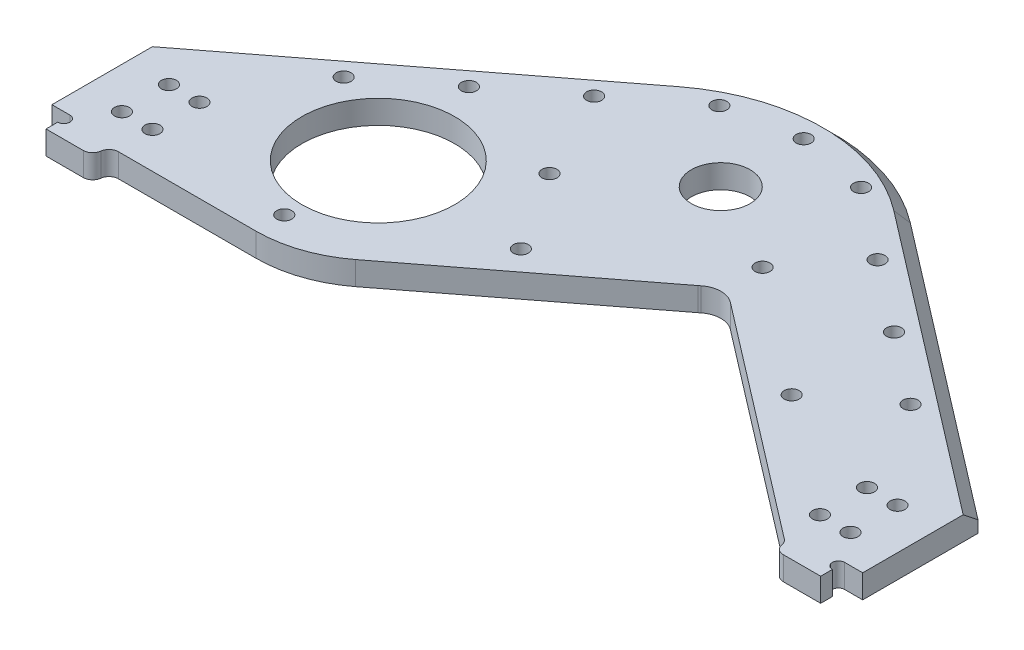
from build123d import *

# Parameters (mm, degrees)
SKETCH3_R                          = 17.8
SKETCH3_R_2                        = 7.9375
BOSS_EXTRUDE1_DEPTH                = 6.35
SKETCH7_R                          = 20.6375
CUT_EXTRUDE1_DEPTH                 = 7.35
SKETCH8_W                          = 4.7498
SKETCH8_H                          = 41.275
BOSS_EXTRUDE4_DEPTH                = 6.35
SKETCH10_R                         = 2.0193
SPACER_HOLES_DEPTH                 = 7.35
SPACER_HOLE_PATTERN_COUNT          = 5
SPACER_HOLE_PATTERN_PITCH          = 24.13
SPACER_HOLE_MIRROR_COPY_1_SKETCH_R = 2.0193
SPACER_HOLE_MIRROR_COPY_1_DEPTH    = 7.35
SPACER_HOLE_MIRROR_COPY_2_SKETCH_R = 2.0193
SPACER_HOLE_MIRROR_COPY_2_DEPTH    = 7.35
SPACER_HOLE_MIRROR_COPY_3_SKETCH_R = 2.0193
SPACER_HOLE_MIRROR_COPY_3_DEPTH    = 7.35
SPACER_HOLE_MIRROR_COPY_4_SKETCH_R = 2.0193
SPACER_HOLE_MIRROR_COPY_4_DEPTH    = 7.35
SPACER_HOLE_MIRROR_COPY_5_SKETCH_R = 2.0193
SPACER_HOLE_MIRROR_COPY_5_DEPTH    = 7.35
SKETCH16_R                         = 2.0193
CUSTOM_NUTSTRIP_HOLES_DEPTH        = 7.35
SKETCH36_R                         = 2.0193
AUX_SPACER_HOLES_DEPTH             = 7.35
SKETCH58_R                         = 2.0193
CUT_EXTRUDE30_DEPTH                = 7.35
SKETCH84_R                         = 2.0193
CUT_EXTRUDE40_DEPTH                = 7.35
CUT_EXTRUDE34_DEPTH                = 7.35
SKETCH105_W                        = 4.8768
SKETCH105_H                        = 6.477
CUT_EXTRUDE54_DEPTH                = 7.35
SKETCH106_R                        = 1.651
CUT_EXTRUDE55_DEPTH                = 7.35
CHAMFER5_SIZE                      = 3.175
FILLET21_R                         = 6.35
FILLET22_R                         = 2.54
FILLET23_R                         = 2.54


with BuildPart() as part:
    # Sketch3 → Boss-Extrude1 (new body)
    with BuildSketch(Plane(origin=(0, 25.4, 0), x_dir=(1, 0, 0), z_dir=(0, 1, 0))):
        with BuildLine():
            Line((-104.775, -36.374686106), (-30.925080594, 20.292350114))
            Line((-30.925080594, 20.292350114), (0, 44.021999059))
            Line((0, 44.021999059), (30.925080594, 20.292350114))
            Line((30.925080594, 20.292350114), (104.775, -36.374686106))
            Line((104.775, -36.374686106), (104.775, -77.649686106))
            Line((104.775, -77.649686106), (92.075, -77.649686106))
            Line((92.075, -77.649686106), (92.075, -74.653632333))
            Line((92.075, -74.653632333), (24.142327736, -22.527059539))
            ThreePointArc((24.142327736, -22.527059539), (22.197769032, -24.445438225), (20.101302386, -26.196527296))
            Line((20.101302386, -26.196527296), (-32.251449857, -66.368206988))
            ThreePointArc((-32.251449857, -66.368206988), (-41.738821099, -71.439312567), (-52.352752243, -73.191679691))
            Line((-52.352752243, -73.191679691), (-92.075, -73.191679691))
            Line((-92.075, -73.191679691), (-92.075, -77.649686106))
            Line((-92.075, -77.649686106), (-104.775, -77.649686106))
            Line((-104.775, -77.649686106), (-104.775, -36.374686106))
        make_face()
        with Locations((-52.352752243, -40.171679691)):
            Circle(SKETCH3_R, mode=Mode.SUBTRACT)
        Circle(SKETCH3_R_2, mode=Mode.SUBTRACT)
    extrude(amount=-BOSS_EXTRUDE1_DEPTH)

    # Sketch7 → Cut-Extrude1 (cut, through all)
    with BuildSketch(Plane(origin=(0, 25.4, 0), x_dir=(1, 0, 0), z_dir=(0, 1, 0))):
        with Locations((-52.352752243, -40.171679691)):
            Circle(SKETCH7_R)
    extrude(amount=-CUT_EXTRUDE1_DEPTH, mode=Mode.SUBTRACT)

    # Sketch8 → Boss-Extrude4 (add, through all)
    with BuildSketch(Plane(origin=(0, 25.4, 0), x_dir=(1, 0, 0), z_dir=(0, 1, 0))):
        with Locations((-107.1499, -57.012186106)):
            Rectangle(SKETCH8_W, SKETCH8_H)
        with Locations((107.1499, -57.012186106)):
            Rectangle(SKETCH8_W, SKETCH8_H)
    extrude(amount=-BOSS_EXTRUDE4_DEPTH)

    # Sketch10 → Spacer Holes (cut, through all)
    with BuildSketch(Plane(origin=(0, 25.4, 0), x_dir=(1, 0, 0), z_dir=(0, 1, 0))):
        with Locations((0, 33.456719285)):
            Circle(SKETCH10_R)
    spacer_holes = extrude(amount=-SPACER_HOLES_DEPTH, mode=Mode.SUBTRACT)

    # Spacer Hole Pattern: Spacer Holes ×5
    with Locations(*[Vector(-0.79335334, 0, 0.608761429) * (i * SPACER_HOLE_PATTERN_PITCH) for i in range(1, SPACER_HOLE_PATTERN_COUNT)]):
        add(spacer_holes, mode=Mode.SUBTRACT)

    # Spacer Hole Mirror copy 1 sketch → Spacer Hole Mirror copy 1 (cut, through all)
    with BuildSketch(Plane(origin=(19.143616101, 25.4, 14.689413282), x_dir=(-1, 0, 0), z_dir=(0, 1, 0))):
        with Locations((0, -33.456719285)):
            Circle(SPACER_HOLE_MIRROR_COPY_1_SKETCH_R)
    extrude(amount=-SPACER_HOLE_MIRROR_COPY_1_DEPTH, mode=Mode.SUBTRACT)

    # Spacer Hole Mirror copy 2 sketch → Spacer Hole Mirror copy 2 (cut, through all)
    with BuildSketch(Plane(origin=(38.287232202, 25.4, 29.378826564), x_dir=(-1, 0, 0), z_dir=(0, 1, 0))):
        with Locations((0, -33.456719285)):
            Circle(SPACER_HOLE_MIRROR_COPY_2_SKETCH_R)
    extrude(amount=-SPACER_HOLE_MIRROR_COPY_2_DEPTH, mode=Mode.SUBTRACT)

    # Spacer Hole Mirror copy 3 sketch → Spacer Hole Mirror copy 3 (cut, through all)
    with BuildSketch(Plane(origin=(57.430848304, 25.4, 44.068239846), x_dir=(-1, 0, 0), z_dir=(0, 1, 0))):
        with Locations((0, -33.456719285)):
            Circle(SPACER_HOLE_MIRROR_COPY_3_SKETCH_R)
    extrude(amount=-SPACER_HOLE_MIRROR_COPY_3_DEPTH, mode=Mode.SUBTRACT)

    # Spacer Hole Mirror copy 4 sketch → Spacer Hole Mirror copy 4 (cut, through all)
    with BuildSketch(Plane(origin=(76.574464405, 25.4, 58.757653128), x_dir=(-1, 0, 0), z_dir=(0, 1, 0))):
        with Locations((0, -33.456719285)):
            Circle(SPACER_HOLE_MIRROR_COPY_4_SKETCH_R)
    extrude(amount=-SPACER_HOLE_MIRROR_COPY_4_DEPTH, mode=Mode.SUBTRACT)

    # Spacer Hole Mirror copy 5 sketch → Spacer Hole Mirror copy 5 (cut, through all)
    with BuildSketch(Plane(origin=(0, 25.4, 0), x_dir=(-1, 0, 0), z_dir=(0, 1, 0))):
        with Locations((0, -33.456719285)):
            Circle(SPACER_HOLE_MIRROR_COPY_5_SKETCH_R)
    extrude(amount=-SPACER_HOLE_MIRROR_COPY_5_DEPTH, mode=Mode.SUBTRACT)

    # Sketch16 → Custom Nutstrip Holes (cut, through all)
    with BuildSketch(Plane(origin=(0, 25.4, 0), x_dir=(1, 0, 0), z_dir=(0, 1, 0))):
        with Locations((-98.425, -50.662186106)):
            Circle(SKETCH16_R)
        with Locations((-98.425, -63.362186106)):
            Circle(SKETCH16_R)
        with Locations((98.425, -63.362186106)):
            Circle(SKETCH16_R)
        with Locations((98.425, -50.662186106)):
            Circle(SKETCH16_R)
    extrude(amount=-CUSTOM_NUTSTRIP_HOLES_DEPTH, mode=Mode.SUBTRACT)

    # Sketch36 → Aux Spacer Holes (cut, through all)
    with BuildSketch(Plane(origin=(0, 25.4, 0), x_dir=(1, 0, 0), z_dir=(0, 1, 0))):
        with Locations((-52.352752243, -65.571679691)):
            Circle(SKETCH36_R)
        with Locations((58.293943402, -39.127716128)):
            Circle(SKETCH36_R)
        with Locations((24.512886804, -13.206599718)):
            Circle(SKETCH36_R)
        with Locations((-12.439980265, -41.561531903)):
            Circle(SKETCH36_R)
        with Locations((-26.176376122, -20.085839846)):
            Circle(SKETCH36_R)
    extrude(amount=-AUX_SPACER_HOLES_DEPTH, mode=Mode.SUBTRACT)

    # Sketch58 → Cut-Extrude30 (cut, through all)
    with BuildSketch(Plane(origin=(0, 25.4, 0), x_dir=(1, 0, 0), z_dir=(0, 1, 0))):
        with Locations((0, 22.408000428)):
            Circle(SKETCH58_R)
        with BuildLine():
            Line((-30.925080594, 20.292350114), (0, 44.021999059))
            Line((0, 44.021999059), (30.925080594, 20.292350114))
            ThreePointArc((30.925080594, 20.292350114), (0, 30.790000428), (-30.925080594, 20.292350114))
        make_face()
    extrude(amount=-CUT_EXTRUDE30_DEPTH, mode=Mode.SUBTRACT)

    # Sketch84 → Cut-Extrude40 (cut, through all)
    with BuildSketch(Plane(origin=(0, 25.4, 0), x_dir=(1, 0, 0), z_dir=(0, 1, 0))):
        with Locations((90.17, -50.662186106)):
            Circle(SKETCH84_R)
        with Locations((90.17, -63.362186106)):
            Circle(SKETCH84_R)
        with Locations((-90.17, -50.662186106)):
            Circle(SKETCH84_R)
        with Locations((-90.17, -63.362186106)):
            Circle(SKETCH84_R)
    extrude(amount=-CUT_EXTRUDE40_DEPTH, mode=Mode.SUBTRACT)

    # Sketch75 → Cut-Extrude34 (cut, through all)
    with BuildSketch(Plane(origin=(0, 25.4, 0), x_dir=(1, 0, 0), z_dir=(0, 1, 0))):
        Polygon((-104.775, -36.374686106), (-109.5248, -40.019335834), (-109.5248, -36.374686106), align=None)
        Polygon((104.775, -36.374686106), (109.5248, -40.019335834), (109.5248, -36.374686106), align=None)
    extrude(amount=-CUT_EXTRUDE34_DEPTH, mode=Mode.SUBTRACT)

    # Sketch105 → Cut-Extrude54 (cut, through all)
    with BuildSketch(Plane(origin=(0, 25.4, 0), x_dir=(1, 0, 0), z_dir=(0, 1, 0))):
        with Locations((-107.0864, -74.411186106)):
            Rectangle(SKETCH105_W, SKETCH105_H)
        with Locations((107.0864, -74.411186106)):
            Rectangle(SKETCH105_W, SKETCH105_H)
    extrude(amount=-CUT_EXTRUDE54_DEPTH, mode=Mode.SUBTRACT)

    # Sketch106 → Cut-Extrude55 (cut, through all)
    with BuildSketch(Plane(origin=(0, 25.4, 0), x_dir=(1, 0, 0), z_dir=(0, 1, 0))):
        with Locations((-104.648, -72.823686106)):
            Circle(SKETCH106_R)
        with Locations((104.648, -72.823686106)):
            Circle(SKETCH106_R)
    extrude(amount=-CUT_EXTRUDE55_DEPTH, mode=Mode.SUBTRACT)

    # Chamfer5
    chamfer5_edges = [part.edges().sort_by_distance(p)[0] for p in [
        (70.224940297, 25.4, 9.86349286),
        (-70.224940297, 25.4, 9.86349286),
        (0, 25.4, -30.790000428),
    ]]
    chamfer(chamfer5_edges, length=CHAMFER5_SIZE)

    # Fillet21
    fillet21_edges = [part.edges().sort_by_distance(p)[0] for p in [
        (24.142327736, 22.225, 22.527059539),
    ]]
    fillet(fillet21_edges, radius=FILLET21_R)

    # Fillet22
    fillet22_edges = [part.edges().sort_by_distance(p)[0] for p in [
        (-92.075, 22.225, 73.191679691),
        (92.075, 22.225, 74.653632333),
    ]]
    fillet(fillet22_edges, radius=FILLET22_R)

    # Fillet23
    fillet23_edges = [part.edges().sort_by_distance(p)[0] for p in [
        (92.075, 22.225, 77.649686106),
        (-92.075, 22.225, 77.649686106),
    ]]
    fillet(fillet23_edges, radius=FILLET23_R)


solid = part.part
